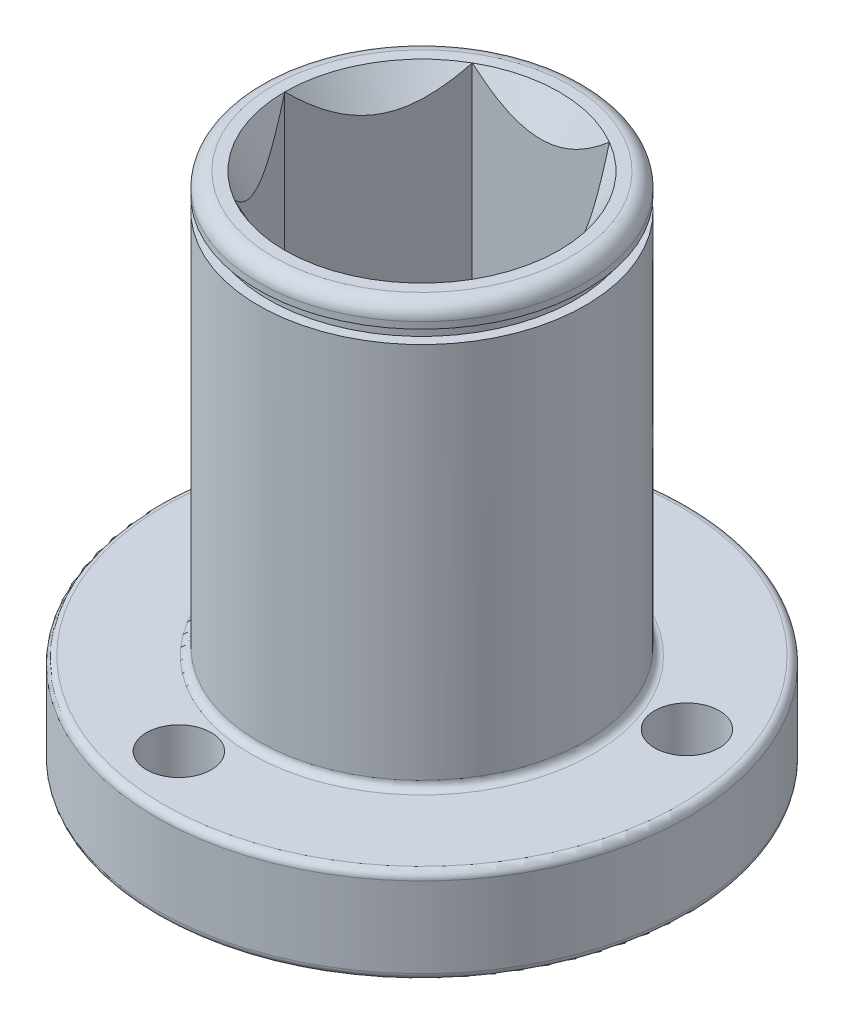
from build123d import *

# Parameters (mm, degrees)
SKETCH2_R                = 28.3845
BOSS_EXTRUDE1_DEPTH      = 10.16
SKETCH3_R                = 17.4625
BOSS_EXTRUDE2_DEPTH      = 44.831
CUT_EXTRUDE1_DEPTH       = 1
CUT_EXTRUDE1_DEPTH_BACK  = 55.991
F_5_16_24_TAPPED_HOLE2_D = 6.9088
SKETCH10_W               = 1.0668
SKETCH10_H               = 1.4224
FILLET1_R                = 1.5875
FILLET2_R                = 0.79375


with BuildPart() as part:
    # Sketch2 → Boss-Extrude1 (new body)
    with BuildSketch(Plane(origin=(0, 0, 0), x_dir=(1, 0, 0), z_dir=(0, 1, 0))):
        Circle(SKETCH2_R)
    extrude(amount=BOSS_EXTRUDE1_DEPTH)

    # Sketch3 → Boss-Extrude2 (add)
    with BuildSketch(Plane(origin=(0, 10.16, 0), x_dir=(1, 0, 0), z_dir=(0, 1, 0))):
        Circle(SKETCH3_R)
    extrude(amount=BOSS_EXTRUDE2_DEPTH)

    # Sketch4 → Cut-Extrude1 (cut, two sides)
    with BuildSketch(Plane(origin=(0, 54.991, 0), x_dir=(1, 0, 0), z_dir=(0, 1, 0))) as cut_extrude1_sk:
        Polygon((14.664696837, 0), (7.332348419, 12.7), (-7.332348419, 12.7), (-14.664696837, 0), (-7.332348419, -12.7), (7.332348419, -12.7), align=None)
    extrude(amount=CUT_EXTRUDE1_DEPTH, mode=Mode.SUBTRACT)
    extrude(cut_extrude1_sk.sketch, amount=-CUT_EXTRUDE1_DEPTH_BACK, mode=Mode.SUBTRACT)

    # 5/16-24 Tapped Hole2 (through all)
    with Locations(Plane(origin=(0, 0, 0), x_dir=(-1, 0, 0), z_dir=(0, -1, 0))):
        with Locations((4.138562858, -21.83627538), (16.841487774, 14.50223826), (-20.980050632, 7.33403712)):
            Hole(F_5_16_24_TAPPED_HOLE2_D / 2)

    # Sketch10 → Cut-Revolve1 (revolve, cut)
    with BuildSketch(Plane.XY):
        Polygon((14.664696837, 54.991), (0, 29.591), (0, 54.991), align=None)
        Polygon((14.664696837, 0), (0, 14.664696837), (0, 0), align=None)
        with Locations((16.9291, 51.9938)):
            Rectangle(SKETCH10_W, SKETCH10_H)
    revolve(axis=Axis((0, 0, 0), (0, 1, 0)), mode=Mode.SUBTRACT)

    # Fillet1
    fillet1_edges = [part.edges().sort_by_distance(p)[0] for p in [
        (-17.4625, 54.991, 0),
    ]]
    fillet(fillet1_edges, radius=FILLET1_R)

    # Fillet2
    fillet2_edges = [part.edges().sort_by_distance(p)[0] for p in [
        (-28.3845, 0, 0),
        (-28.3845, 10.16, 0),
        (-17.4625, 10.16, 0),
    ]]
    fillet(fillet2_edges, radius=FILLET2_R)


solid = part.part
